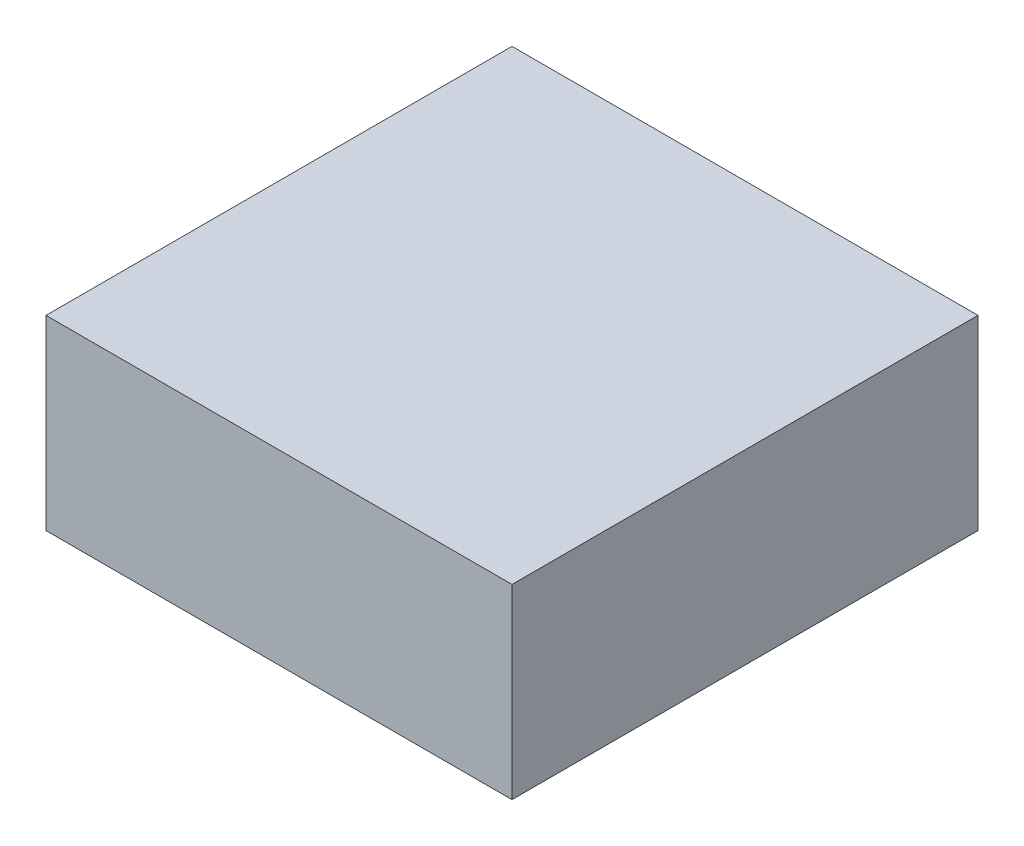
from build123d import *

# Parameters (mm, degrees)
SKETCH1_W           = 0.5
SKETCH1_H           = 0.5
BOSS_EXTRUDE1_DEPTH = 0.2


with BuildPart() as part:
    # Sketch1 → Boss-Extrude1 (new body)
    with BuildSketch(Plane(origin=(0, 0, 0), x_dir=(1, 0, 0), z_dir=(0, 1, 0))):
        with Locations((-0.25, 0.25)):
            Rectangle(SKETCH1_W, SKETCH1_H)
    extrude(amount=BOSS_EXTRUDE1_DEPTH)


solid = part.part
